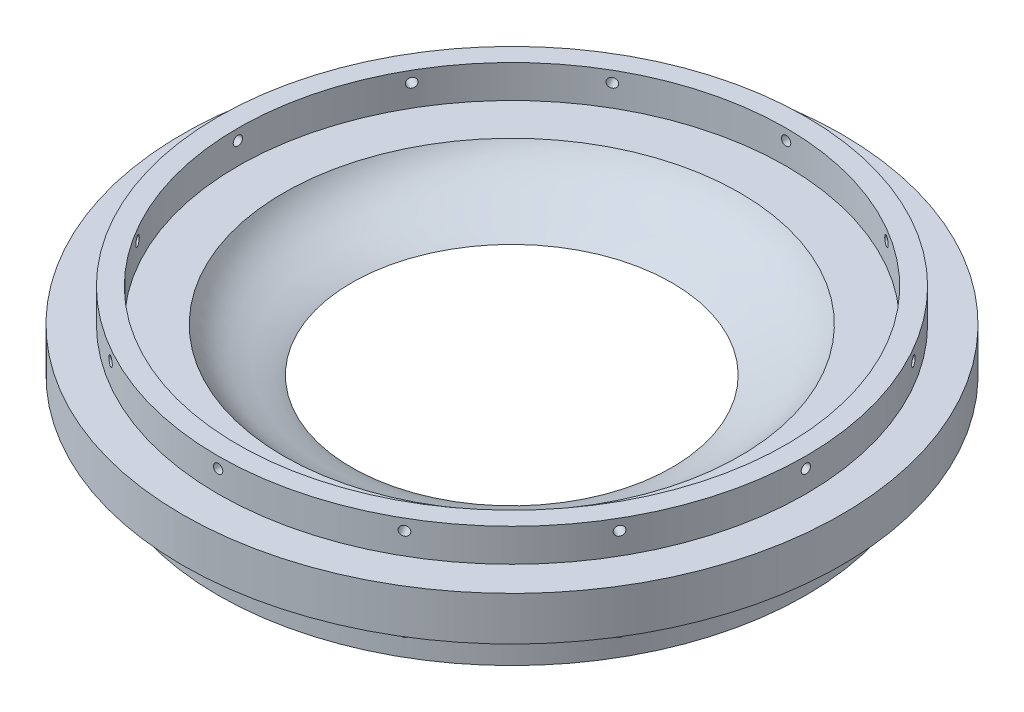
from build123d import *

# Parameters (mm, degrees)
SKETCH1_W           = 127.635
SKETCH1_H           = 127.635
BOSS_EXTRUDE1_DEPTH = 12.7
SKETCH12_R          = 95.4151
BOSS_EXTRUDE2_DEPTH = 12.7
SKETCH5_R           = 46.355
CUT_EXTRUDE1_DEPTH  = 9.525
SKETCH30_R          = 85.09
SKETCH30_R_2        = 79.375
BOSS_EXTRUDE3_DEPTH = 12.7
SKETCH32_R          = 1.35255
CUT_EXTRUDE4_DEPTH  = 15.24
CIRPATTERN2_COUNT   = 12


with BuildPart() as part:
    # Sketch1 → Boss-Extrude1 (new body)
    with BuildSketch(Plane(origin=(0, 0, 0), x_dir=(1, 0, 0), z_dir=(0, 1, 0))):
        with Locations((63.8175, 63.8175)):
            Rectangle(SKETCH1_W, SKETCH1_H)
    extrude(amount=BOSS_EXTRUDE1_DEPTH)

    # Sketch12 → Boss-Extrude2 (add)
    with BuildSketch(Plane.XZ):
        with Locations((63.8175, -63.8175)):
            Circle(SKETCH12_R)
    extrude(amount=-BOSS_EXTRUDE2_DEPTH)

    # Sketch5 → Cut-Extrude1 (cut)
    with BuildSketch(Plane(origin=(0, 12.7, 0), x_dir=(1, 0, 0), z_dir=(0, 1, 0))):
        with Locations((63.8175, 63.8175)):
            Circle(SKETCH5_R)
    extrude(amount=-CUT_EXTRUDE1_DEPTH, mode=Mode.SUBTRACT)

    # Sketch30 → Boss-Extrude3 (add)
    with BuildSketch(Plane.XZ):
        with Locations((63.8175, -63.8175)):
            Circle(SKETCH30_R)
        with Locations((63.8175, -63.8175)):
            Circle(SKETCH30_R_2, mode=Mode.SUBTRACT)
    boss_extrude3 = extrude(amount=BOSS_EXTRUDE3_DEPTH)

    # Mirror1: Boss-Extrude3 across plane
    add(boss_extrude3.mirror(Plane.ZX.offset(4.7625)))

    # Sketch32 → Cut-Extrude4 (cut)
    with BuildSketch(Plane(origin=(0, 0, -148.9075), x_dir=(-1, 0, 0), z_dir=(0, 0, -1))):
        with Locations((-63.8175, -6.35)):
            Circle(SKETCH32_R)
        with Locations((-63.8175, 19.05)):
            Circle(SKETCH32_R)
    cut_extrude4 = extrude(amount=-CUT_EXTRUDE4_DEPTH, mode=Mode.SUBTRACT)

    # CirPattern2: Cut-Extrude4 ×12 about axis
    cirpattern2_axis = Axis((63.8175, -12.7, -63.8175), (0, 1, 0))
    for i in range(1, CIRPATTERN2_COUNT):
        add(cut_extrude4.rotate(cirpattern2_axis, i * 360 / CIRPATTERN2_COUNT), mode=Mode.SUBTRACT)

    # Sketch35 → Cut-Revolve1 (revolve, cut)
    with BuildSketch(Plane.XY.offset(-63.754)):
        with BuildLine():
            add(Edge.make_bspline(
                [(129.8575, 12.7), (125.556720128, 5.300210603), (116.945262531, 3.999403305), (110.1725, 0)],
                knots=[0, 0, 0, 0, 1, 1, 1, 1], degree=3))
            Line((110.1725, 0), (63.8175, 0))
            Line((63.8175, 0), (63.8175, 12.7))
            Line((63.8175, 12.7), (129.8575, 12.7))
        make_face()
    revolve(axis=Axis((63.8175, -10.330163638, -63.754), (0, 1, 0)), mode=Mode.SUBTRACT)


solid = part.part
